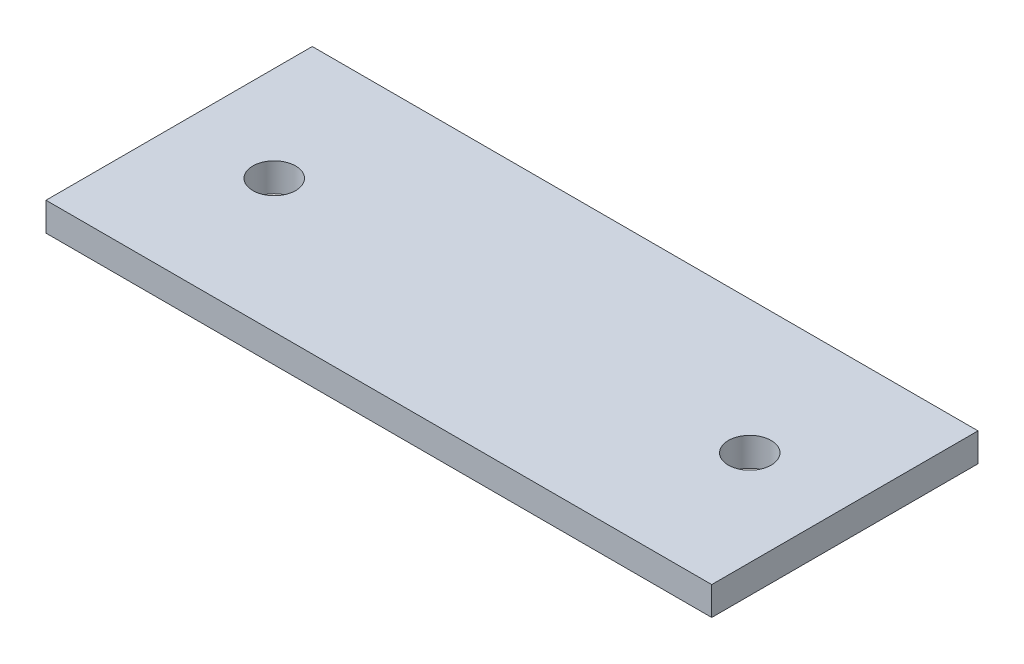
from build123d import *

# Parameters (mm, degrees)
SKETCH1_W           = 70
SKETCH1_H           = 28
SKETCH1_R           = 2.25
BOSS_EXTRUDE1_DEPTH = 3


with BuildPart() as part:
    # Sketch1 → Boss-Extrude1 (new body)
    with BuildSketch(Plane(origin=(0, 0, 0), x_dir=(1, 0, 0), z_dir=(0, 1, 0))):
        with Locations((35, 14)):
            Rectangle(SKETCH1_W, SKETCH1_H)
        with Locations((10, 14)):
            Circle(SKETCH1_R, mode=Mode.SUBTRACT)
        with Locations((60, 14)):
            Circle(SKETCH1_R, mode=Mode.SUBTRACT)
    extrude(amount=BOSS_EXTRUDE1_DEPTH)


solid = part.part
